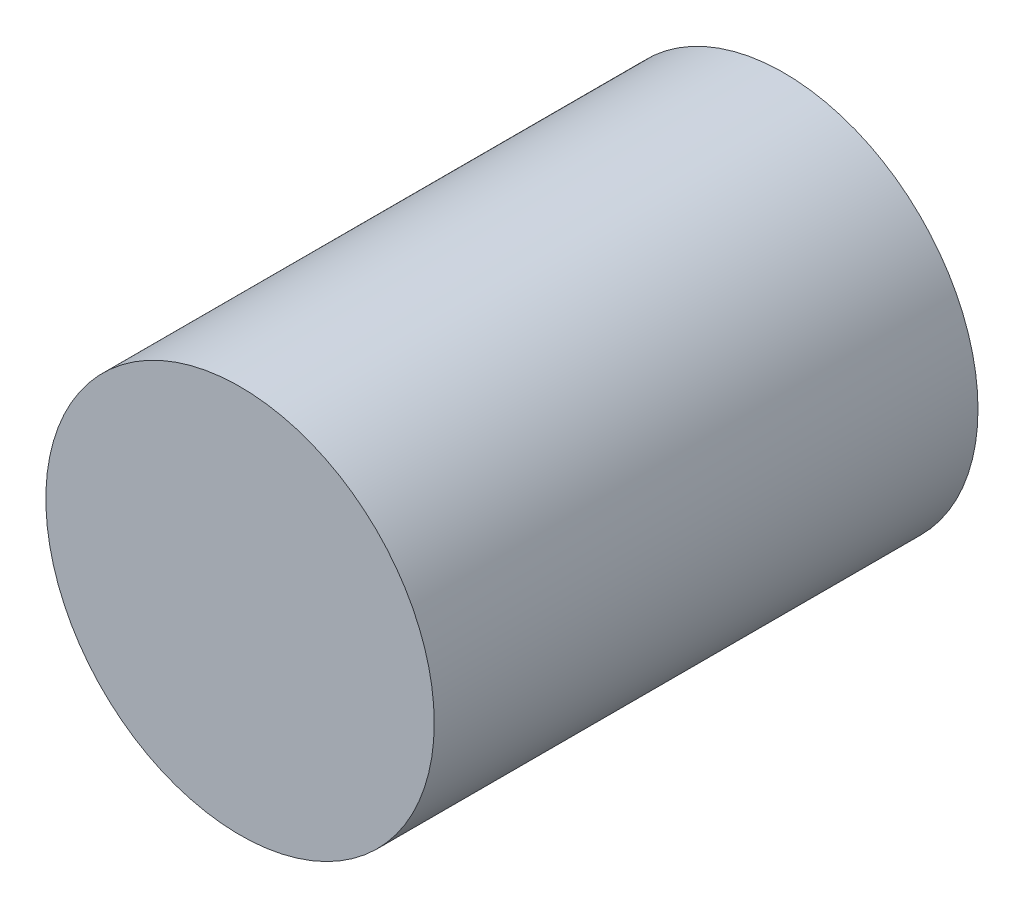
from build123d import *


with BuildPart() as part:
    # Croquis1 → Revolución1 (revolve)
    with BuildSketch(Plane(origin=(0, 0, 0), x_dir=(0, 0, -1), z_dir=(1, 0, 0))):
        Polygon((0, 0), (0, 50), (140, 50), (140, 30), (100, 30), (100, 10), (20, 10), (20, 0), align=None)
    revolve(axis=Axis((0, 0, 0), (0, 0, -1)))


solid = part.part
